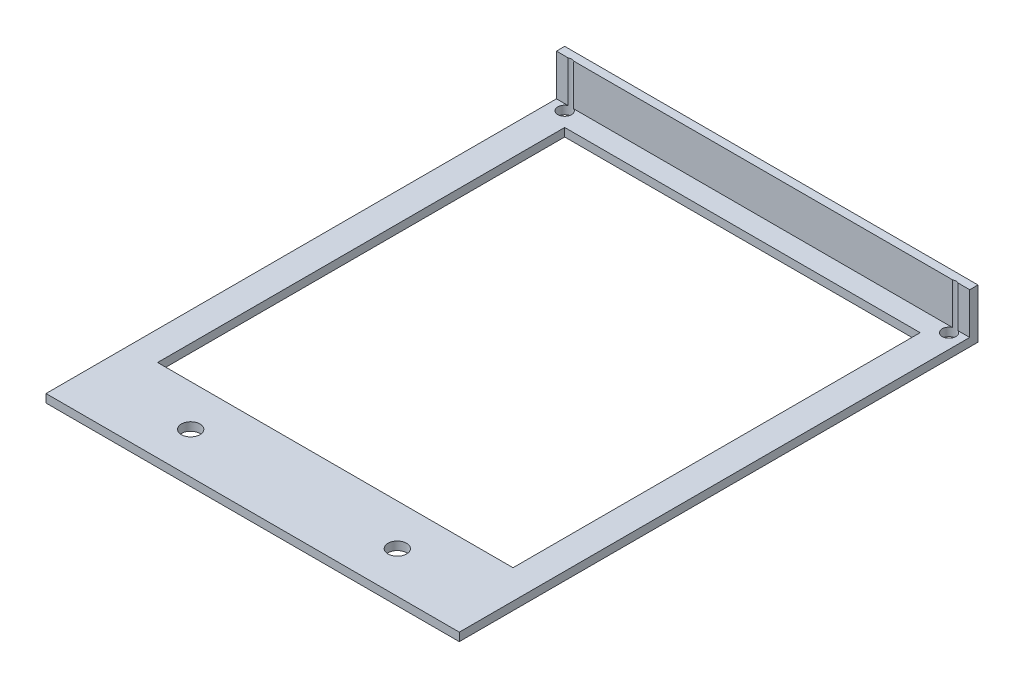
from build123d import *

# Parameters (mm, degrees)
SKETCH1_W                      = 96
SKETCH1_H                      = 121.5
SKETCH1_W_2                    = 86
SKETCH1_H_2                    = 98.5
BOSS_EXTRUDE1_DEPTH            = 2
SKETCH2_W                      = 100
SKETCH2_H                      = 125.5
SKETCH2_W_2                    = 96
SKETCH2_H_2                    = 121.5
BOSS_EXTRUDE2_DEPTH            = 2
SKETCH8_W                      = 100
SKETCH8_H                      = 2
BOSS_EXTRUDE6_DEPTH            = 10
CUT_EXTRUDE1_REACH             = 14
SKETCH3_R                      = 2.25
SKETCH3_R_2                    = 1.65
CUT_EXTRUDE1_DIRECTION_2_DEPTH = 1


with BuildPart() as part:
    # Sketch1 → Boss-Extrude1 (new body)
    with BuildSketch(Plane(origin=(0, 0, 0), x_dir=(1, 0, 0), z_dir=(0, 1, 0))):
        Rectangle(SKETCH1_W, SKETCH1_H)
        with Locations((0, 6.5)):
            Rectangle(SKETCH1_W_2, SKETCH1_H_2, mode=Mode.SUBTRACT)
    extrude(amount=BOSS_EXTRUDE1_DEPTH)

    # Sketch2 → Boss-Extrude2 (add)
    with BuildSketch(Plane(origin=(0, 0, 0), x_dir=(1, 0, 0), z_dir=(0, 1, 0))):
        Rectangle(SKETCH2_W, SKETCH2_H)
        Rectangle(SKETCH2_W_2, SKETCH2_H_2, mode=Mode.SUBTRACT)
    extrude(amount=BOSS_EXTRUDE2_DEPTH)

    # Sketch8 → Boss-Extrude6 (add)
    with BuildSketch(Plane(origin=(0, 2, 0), x_dir=(1, 0, 0), z_dir=(0, 1, 0))):
        with Locations((0, 61.75)):
            Rectangle(SKETCH8_W, SKETCH8_H)
    extrude(amount=BOSS_EXTRUDE6_DEPTH)

    # Sketch3 → Cut-Extrude1 (cut, up to next)
    with BuildSketch(Plane.XZ, mode=Mode.PRIVATE) as cut_extrude1_sk1:
        with Locations((25, 52.75)):
            Circle(SKETCH3_R)
    cut_extrude1_tool1 = extrude(cut_extrude1_sk1.sketch, amount=-CUT_EXTRUDE1_REACH, mode=Mode.PRIVATE) & part.part
    add(cut_extrude1_tool1.solids().sort_by_distance((25, 0, 52.75))[0], mode=Mode.SUBTRACT)
    # Sketch3 → Cut-Extrude1 (cut, up to next)
    with BuildSketch(Plane.XZ, mode=Mode.PRIVATE) as cut_extrude1_sk2:
        with Locations((-25, 52.75)):
            Circle(SKETCH3_R)
    cut_extrude1_tool2 = extrude(cut_extrude1_sk2.sketch, amount=-CUT_EXTRUDE1_REACH, mode=Mode.PRIVATE) & part.part
    add(cut_extrude1_tool2.solids().sort_by_distance((-25, 0, 52.75))[0], mode=Mode.SUBTRACT)
    # Sketch3 → Cut-Extrude1 (cut, up to next)
    with BuildSketch(Plane.XZ, mode=Mode.PRIVATE) as cut_extrude1_sk3:
        with Locations((46.5, -59.25)):
            Circle(SKETCH3_R_2)
    cut_extrude1_tool3 = extrude(cut_extrude1_sk3.sketch, amount=-CUT_EXTRUDE1_REACH, mode=Mode.PRIVATE) & part.part
    add(cut_extrude1_tool3.solids().sort_by_distance((46.5, 0, -59.25))[0], mode=Mode.SUBTRACT)
    # Sketch3 → Cut-Extrude1 (cut, up to next)
    with BuildSketch(Plane.XZ, mode=Mode.PRIVATE) as cut_extrude1_sk4:
        with Locations((-46.5, -59.25)):
            Circle(SKETCH3_R_2)
    cut_extrude1_tool4 = extrude(cut_extrude1_sk4.sketch, amount=-CUT_EXTRUDE1_REACH, mode=Mode.PRIVATE) & part.part
    add(cut_extrude1_tool4.solids().sort_by_distance((-46.5, 0, -59.25))[0], mode=Mode.SUBTRACT)

    # Sketch3 → Cut-Extrude1 direction 2 (cut)
    with BuildSketch(Plane.XZ):
        with Locations((25, 52.75)):
            Circle(SKETCH3_R)
        with Locations((-25, 52.75)):
            Circle(SKETCH3_R)
        with Locations((46.5, -59.25)):
            Circle(SKETCH3_R_2)
        with Locations((-46.5, -59.25)):
            Circle(SKETCH3_R_2)
    extrude(amount=CUT_EXTRUDE1_DIRECTION_2_DEPTH, mode=Mode.SUBTRACT)


solid = part.part
